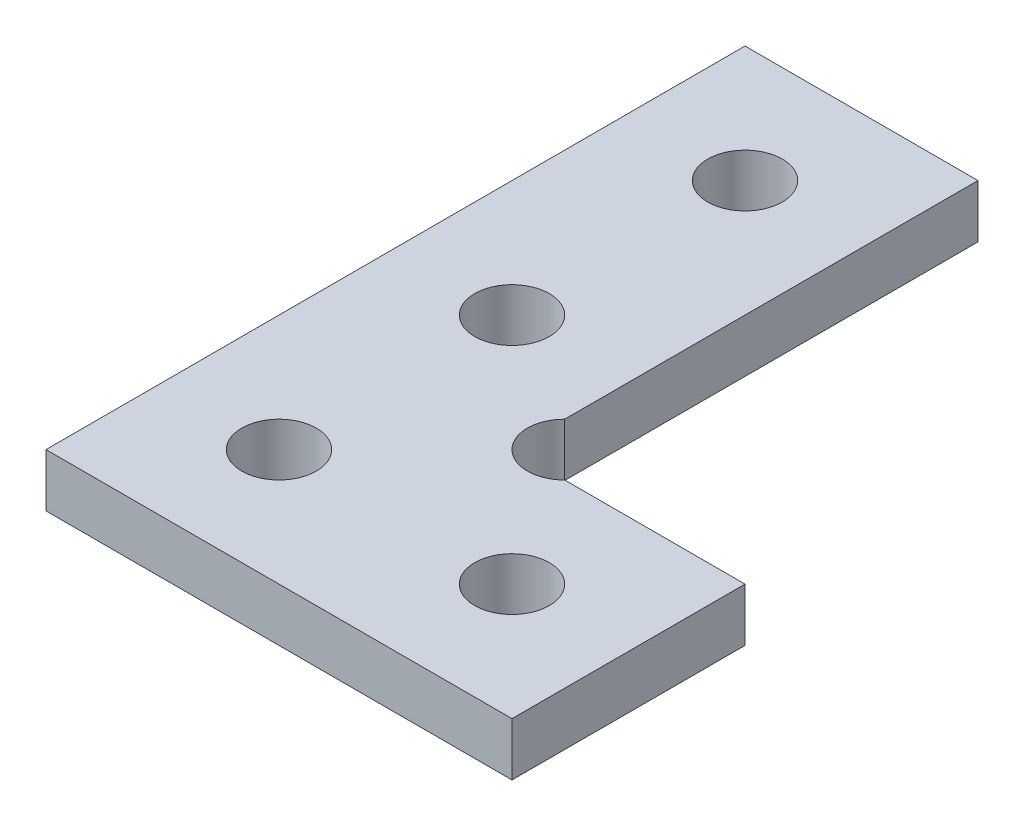
from build123d import *

# Parameters (mm, degrees)
BOSS_EXTRUDE1_DEPTH            = 1.14
F_3_2_3_2_DIAMETER_HOLE1_D     = 3.2
F_3_2_3_2_DIAMETER_HOLE1_DEPTH = 10
F_3_2_3_2_DIAMETER_HOLE1_TIP   = 0.96137699


with BuildPart() as part:
    # Sketch1 → Boss-Extrude1 (new body, symmetric)
    with BuildSketch(Plane(origin=(0, 0, 2279.99997139), x_dir=(1, 0, 0), z_dir=(0, 1, 0))):
        with BuildLine():
            Line((10, 2292.262711431), (10, 2309.99997139))
            Line((10, 2309.99997139), (0, 2309.99997139))
            Line((0, 2309.99997139), (0, 2279.99997139))
            Line((0, 2279.99997139), (20, 2279.99997139))
            Line((20, 2279.99997139), (20, 2289.99997139))
            Line((20, 2289.99997139), (12.262740041, 2289.99997139))
            ThreePointArc((12.262740041, 2289.99997139), (9.99862915, 2289.99860054), (10, 2292.262711431))
        make_face()
    extrude(amount=BOSS_EXTRUDE1_DEPTH, both=True)

    # Ø3.2 (3.2) Diameter Hole1
    with Locations(Plane(origin=(0, 1.14, 0), x_dir=(1, 0, 0), z_dir=(0, 1, 0))):
        with Locations((5, 25), (5, 5), (15, 5), (5, 15)):
            Hole(F_3_2_3_2_DIAMETER_HOLE1_D / 2, depth=F_3_2_3_2_DIAMETER_HOLE1_DEPTH)
            with Locations((0, 0, -(F_3_2_3_2_DIAMETER_HOLE1_DEPTH + F_3_2_3_2_DIAMETER_HOLE1_TIP / 2))):  # 118° drill point
                Cone(0, F_3_2_3_2_DIAMETER_HOLE1_D / 2, F_3_2_3_2_DIAMETER_HOLE1_TIP, mode=Mode.SUBTRACT)


solid = part.part
